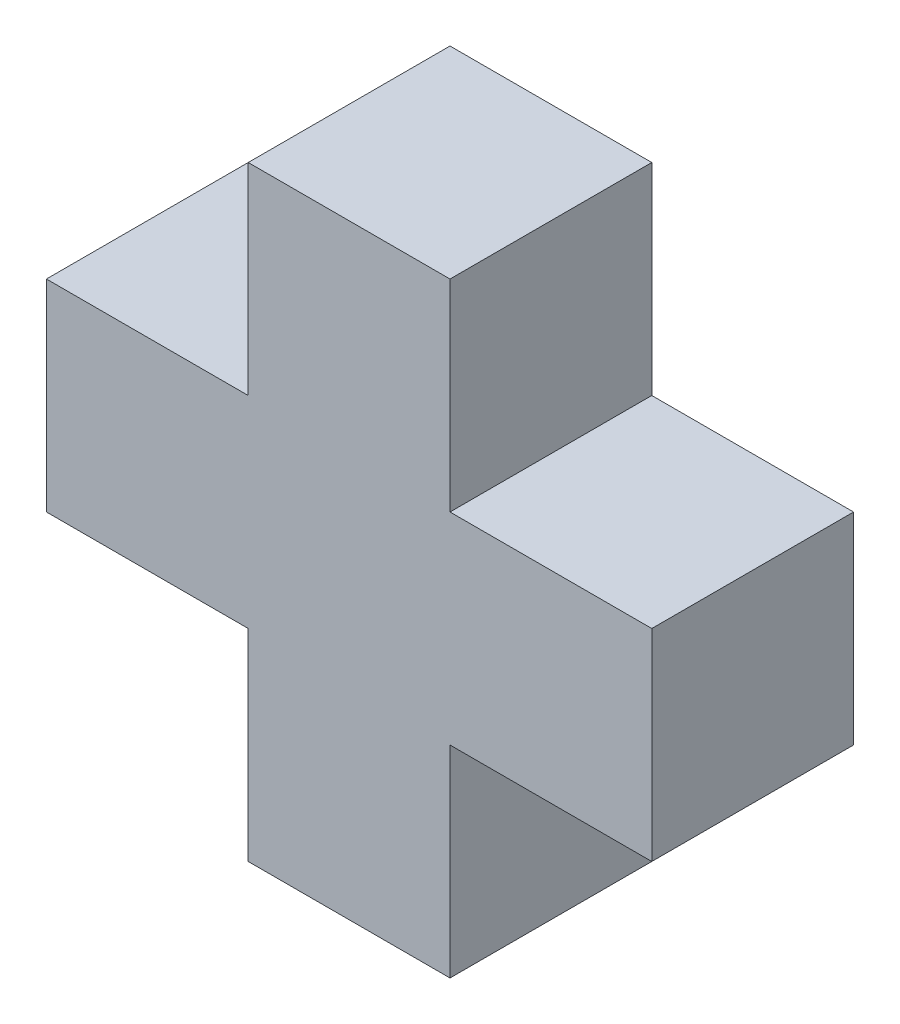
from build123d import *

# Parameters (mm, degrees)
BOSS_EXTRUDE1_DEPTH = 25.4


with BuildPart() as part:
    # Sketch1 → Boss-Extrude1 (new body)
    with BuildSketch(Plane.XY):
        Polygon((25.4, 0), (25.4, 25.4), (0, 25.4), (0, 50.8), (25.4, 50.8), (25.4, 76.2), (50.8, 76.2), (50.8, 50.8), (76.2, 50.8), (76.2, 25.4), (50.8, 25.4), (50.8, 0), align=None)
    extrude(amount=BOSS_EXTRUDE1_DEPTH)


solid = part.part
